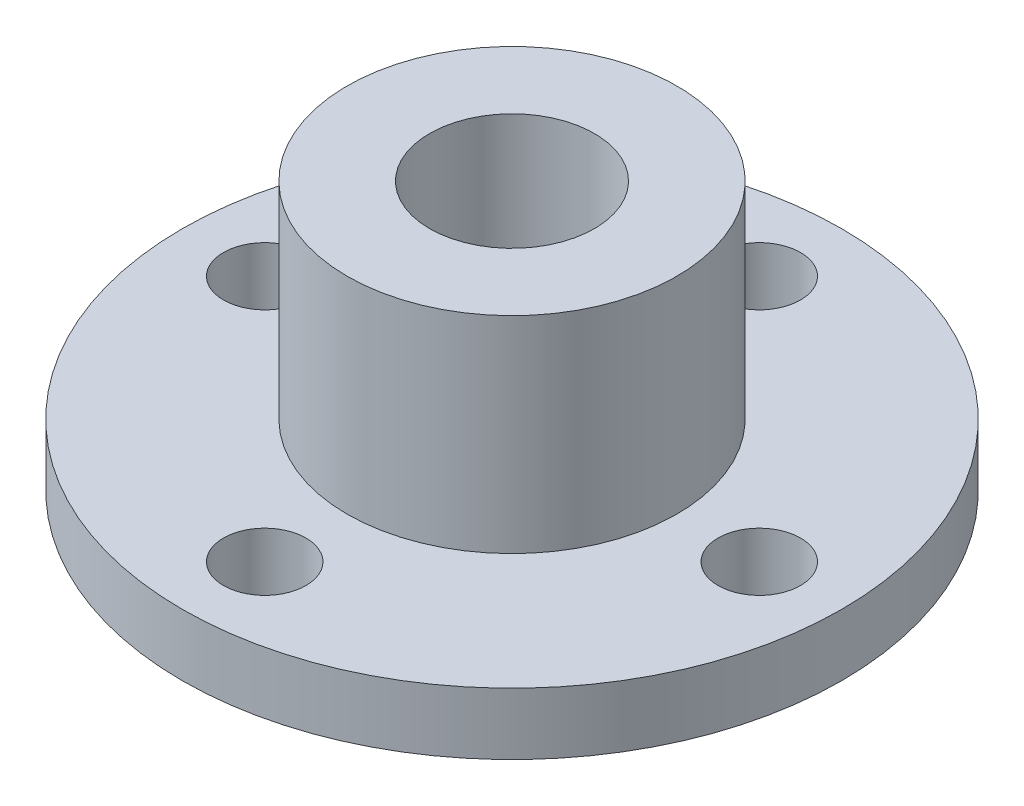
from build123d import *

# Parameters (mm, degrees)
SKETCH2_R           = 16
SKETCH2_R_2         = 2
BOSS_EXTRUDE1_DEPTH = 3
SKETCH3_R           = 8
SKETCH3_R_2         = 4
BOSS_EXTRUDE2_DEPTH = 10
SKETCH4_R           = 2
CUT_EXTRUDE1_DEPTH  = 59


with BuildPart() as part:
    # Sketch2 → Boss-Extrude1 (new body)
    with BuildSketch(Plane(origin=(0, 0, 0), x_dir=(1, 0, 0), z_dir=(0, 1, 0))):
        Circle(SKETCH2_R)
        with Locations((0, 12)):
            Circle(SKETCH2_R_2, mode=Mode.SUBTRACT)
        with Locations((-12, 0)):
            Circle(SKETCH2_R_2, mode=Mode.SUBTRACT)
        with Locations((12, 0)):
            Circle(SKETCH2_R_2, mode=Mode.SUBTRACT)
    extrude(amount=BOSS_EXTRUDE1_DEPTH)

    # Sketch3 → Boss-Extrude2 (add)
    with BuildSketch(Plane(origin=(0, 3, 0), x_dir=(1, 0, 0), z_dir=(0, 1, 0))):
        Circle(SKETCH3_R)
        Circle(SKETCH3_R_2, mode=Mode.SUBTRACT)
    extrude(amount=BOSS_EXTRUDE2_DEPTH)

    # Sketch4 → Cut-Extrude1 (cut)
    with BuildSketch(Plane(origin=(0, 3, 0), x_dir=(1, 0, 0), z_dir=(0, 1, 0))):
        with Locations((0, -12)):
            Circle(SKETCH4_R)
    extrude(amount=-CUT_EXTRUDE1_DEPTH, mode=Mode.SUBTRACT)


solid = part.part
